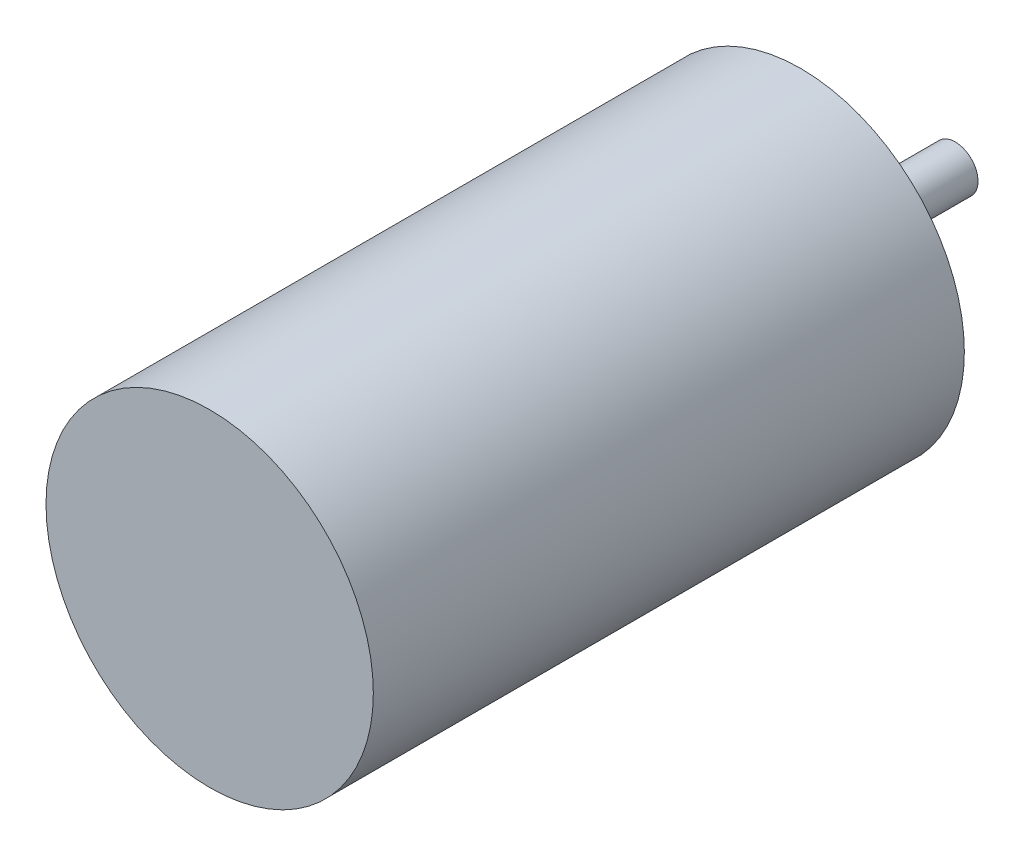
from build123d import *

# Parameters (mm, degrees)
SKETCH1_R           = 18
BOSS_EXTRUDE1_DEPTH = 65
SKETCH2_R           = 2.5
BOSS_EXTRUDE2_DEPTH = 17


with BuildPart() as part:
    # Sketch1 → Boss-Extrude1 (new body)
    with BuildSketch(Plane.XY):
        Circle(SKETCH1_R)
    extrude(amount=BOSS_EXTRUDE1_DEPTH)

    # Sketch2 → Boss-Extrude2 (add)
    with BuildSketch(Plane(origin=(0, 0, 0), x_dir=(-1, 0, 0), z_dir=(0, 0, -1))):
        Circle(SKETCH2_R)
    extrude(amount=BOSS_EXTRUDE2_DEPTH)


solid = part.part
